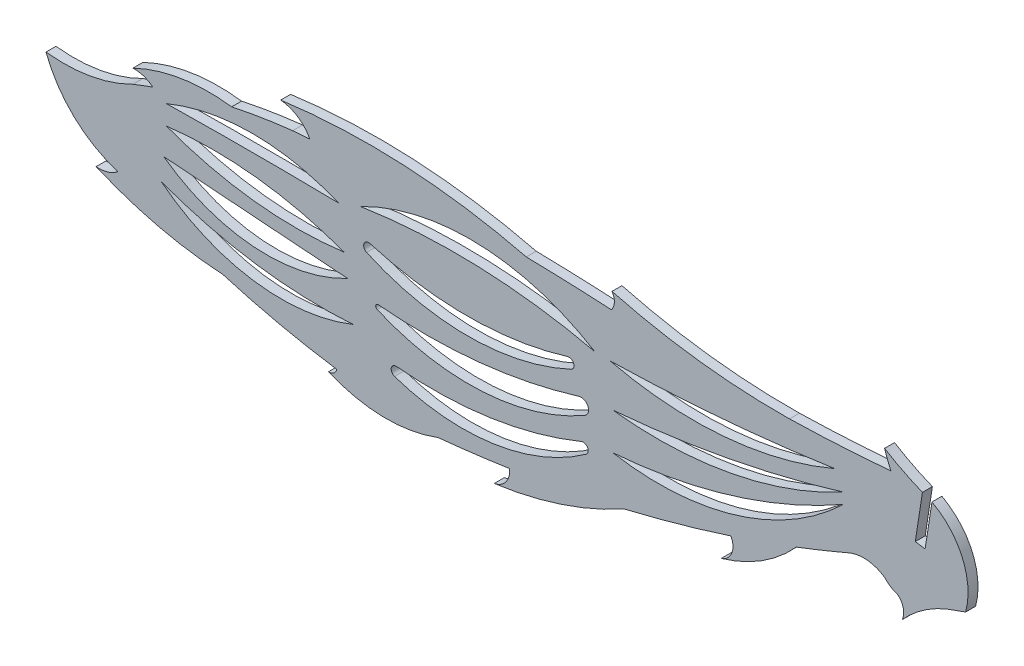
from build123d import *

# Parameters (mm, degrees)
BOSS_EXTRUDE1_DEPTH = 1.524


with BuildPart() as part:
    # Model → Boss-Extrude1 (new body)
    with BuildSketch(Plane.XY):
        with BuildLine():
            Line((125.457442265, 29.854729058), (124.36118777, 22.768051361))
            Line((124.36118777, 22.768051361), (125.867274198, 22.535071382))
            Line((125.867274198, 22.535071382), (126.914488667, 29.304732487))
            ThreePointArc((126.914488667, 29.304732487), (131.596034511, 24.191259053), (132.080813549, 17.27537362))
            Line((132.080813549, 17.27537362), (129.201538518, 16.231235276))
            ThreePointArc((129.201538518, 16.231235276), (125.494314224, 14.202109959), (122.342593367, 11.386525267))
            ThreePointArc((122.342593367, 11.386525267), (122.521547644, 13.015286897), (121.637755911, 14.395069943))
            ThreePointArc((121.637755911, 14.395069943), (120.558535261, 14.894839146), (119.655012959, 15.668230327))
            ThreePointArc((119.655012959, 15.668230327), (116.945656671, 16.627230011), (114.111435919, 16.150276533))
            ThreePointArc((114.111435919, 16.150276533), (110.130348083, 14.492411945), (106.116427247, 12.915701804))
            ThreePointArc((106.116427247, 12.915701804), (100.871077069, 8.483544727), (94.612309809, 5.65767367))
            ThreePointArc((94.612309809, 5.65767367), (96.234412345, 7.167311858), (96.088279041, 9.378390589))
            ThreePointArc((96.088279041, 9.378390589), (87.959563224, 6.916430033), (79.738932416, 4.781365698))
            ThreePointArc((79.738932416, 4.781365698), (70.087015382, 0.573629162), (59.825334355, -1.784855875))
            ThreePointArc((59.825334355, -1.784855875), (61.625546567, -0.674388225), (62.177186804, 1.367570505))
            ThreePointArc((62.177186804, 1.367570505), (56.69945513, 0.613180121), (51.20394484, 0.001611808))
            ThreePointArc((51.20394484, 0.001611808), (42.783253785, -1.45847583), (34.430253575, 0.349086412))
            ThreePointArc((34.430253575, 0.349086412), (35.242407465, 0.582998344), (35.696308866, 1.295937508))
            ThreePointArc((35.696308866, 1.295937508), (26.899874012, 2.912690878), (18.24226034, 5.156991018))
            ThreePointArc((18.24226034, 5.156991018), (8.327270493, 6.613476825), (-1.186477097, 9.762600728))
            ThreePointArc((-1.186477097, 9.762600728), (0.567723509, 9.933888345), (2.129376981, 10.751077214))
            ThreePointArc((2.129376981, 10.751077214), (-4.564424076, 14.67509235), (-8.866303828, 21.132545253))
            ThreePointArc((-8.866303828, 21.132545253), (-2.028267146, 21.342243043), (4.458921798, 23.51459164))
            ThreePointArc((4.458921798, 23.51459164), (5.978589155, 24.100559155), (7.508094135, 24.660346004))
            ThreePointArc((7.508094135, 24.660346004), (6.073839254, 25.435989759), (4.458921798, 25.661271599))
            ThreePointArc((4.458921798, 25.661271599), (11.846812063, 27.976344953), (19.588212991, 28.082169784))
            ThreePointArc((19.588212991, 28.082169784), (24.23969735, 28.951914388), (28.92877134, 29.588583491))
            ThreePointArc((28.92877134, 29.588583491), (30.250891965, 29.696247396), (31.57341018, 29.798912074))
            ThreePointArc((31.57341018, 29.798912074), (29.710039, 31.839896858), (27.095456614, 32.73529062))
            ThreePointArc((27.095456614, 32.73529062), (46.017315853, 33.521760077), (64.749650783, 30.73699449))
            ThreePointArc((64.749650783, 30.73699449), (71.265909378, 30.552300799), (77.77761193, 30.246575893))
            ThreePointArc((77.77761193, 30.246575893), (78.240878226, 31.474299031), (77.877808016, 32.73529062))
            ThreePointArc((77.877808016, 32.73529062), (91.368554355, 30.154894712), (105.083859187, 29.413886469))
            ThreePointArc((105.083859187, 29.413886469), (112.860951548, 29.721873992), (120.624125013, 30.279690879))
            ThreePointArc((120.624125013, 30.279690879), (120.101426826, 31.522338532), (119.655012959, 32.794384617))
            ThreePointArc((119.655012959, 32.794384617), (122.492136598, 31.198051004), (125.457442265, 29.854729058))
        make_face()
        with BuildLine():
            ThreePointArc((113.344379689, 22.19615093), (96.963122218, 12.553503985), (77.990394499, 11.386525267))
            ThreePointArc((77.990394499, 11.386525267), (96.271224533, 14.816426058), (113.344379689, 22.19615093))
        make_face(mode=Mode.SUBTRACT)
        with BuildLine():
            ThreePointArc((113.344379689, 23.82080051), (96.187450512, 17.719248724), (77.990394499, 17.043744891))
            ThreePointArc((77.990394499, 17.043744891), (95.848162694, 19.489217449), (113.344379689, 23.82080051))
        make_face(mode=Mode.SUBTRACT)
        with BuildLine():
            ThreePointArc((112.010038699, 26.273742515), (95.04541072, 22.055495603), (77.613248587, 23.363904105))
            ThreePointArc((77.613248587, 23.363904105), (94.856261251, 24.29140484), (112.010038699, 26.273742515))
        make_face(mode=Mode.SUBTRACT)
        with BuildLine():
            ThreePointArc((73.920433764, 9.144198092), (59.762067232, 3.425519676), (44.552717894, 4.781365698))
            ThreePointArc((44.552717894, 4.781365698), (44.052345371, 5.659967485), (44.86760609, 6.258017419))
            ThreePointArc((44.86760609, 6.258017419), (59.284947166, 6.637177896), (73.189879005, 10.465540071))
            ThreePointArc((73.189879005, 10.465540071), (74.143785851, 10.130315533), (73.920433764, 9.144198092))
        make_face(mode=Mode.SUBTRACT)
        with BuildLine():
            ThreePointArc((73.7171882, 14.19085222), (74.195068041, 15.63804442), (72.809895852, 16.27367986))
            ThreePointArc((72.809895852, 16.27367986), (57.603683966, 13.161162203), (42.082533848, 13.058472776))
            ThreePointArc((42.082533848, 13.058472776), (41.678568271, 12.772614258), (41.897709615, 12.328902245))
            ThreePointArc((41.897709615, 12.328902245), (58.027223609, 9.504074716), (73.7171882, 14.19085222))
        make_face(mode=Mode.SUBTRACT)
        with BuildLine():
            ThreePointArc((71.615953494, 19.263251529), (72.005249, 20.227653753), (71.069824737, 20.682190977))
            ThreePointArc((71.069824737, 20.682190977), (55.942470801, 18.367444511), (40.793050931, 20.533077418))
            ThreePointArc((40.793050931, 20.533077418), (39.862149142, 20.069348511), (40.260924923, 19.10882755))
            ThreePointArc((40.260924923, 19.10882755), (55.955346454, 15.753106638), (71.615953494, 19.263251529))
        make_face(mode=Mode.SUBTRACT)
        with BuildLine():
            ThreePointArc((75.249897816, 23.419828185), (57.358073705, 25.777828917), (39.34157015, 24.737090166))
            ThreePointArc((39.34157015, 24.737090166), (57.468271047, 28.781788902), (75.249897816, 23.419828185))
        make_face(mode=Mode.SUBTRACT)
        with BuildLine():
            ThreePointArc((38.218093055, 8.509361046), (23.282181122, 9.069608784), (8.79939997, 12.763440518))
            ThreePointArc((8.79939997, 12.763440518), (22.937130999, 6.683446576), (38.218093055, 8.509361046))
        make_face(mode=Mode.SUBTRACT)
        with BuildLine():
            ThreePointArc((37.366333435, 14.19085222), (23.274365612, 15.219049254), (9.184351398, 16.27367986))
            ThreePointArc((9.184351398, 16.27367986), (22.976923316, 11.194465897), (37.366333435, 14.19085222))
        make_face(mode=Mode.SUBTRACT)
        with BuildLine():
            ThreePointArc((36.84813704, 17.413649418), (23.030567399, 17.299167045), (9.596276919, 20.533077418))
            ThreePointArc((9.596276919, 20.533077418), (23.40846607, 20.600554903), (36.84813704, 17.413649418))
        make_face(mode=Mode.SUBTRACT)
        with BuildLine():
            ThreePointArc((35.94161169, 23.51459164), (22.768944305, 23.628526918), (9.596276919, 23.51459164))
            ThreePointArc((9.596276919, 23.51459164), (22.768944305, 26.146058656), (35.94161169, 23.51459164))
        make_face(mode=Mode.SUBTRACT)
    extrude(amount=BOSS_EXTRUDE1_DEPTH)


solid = part.part
